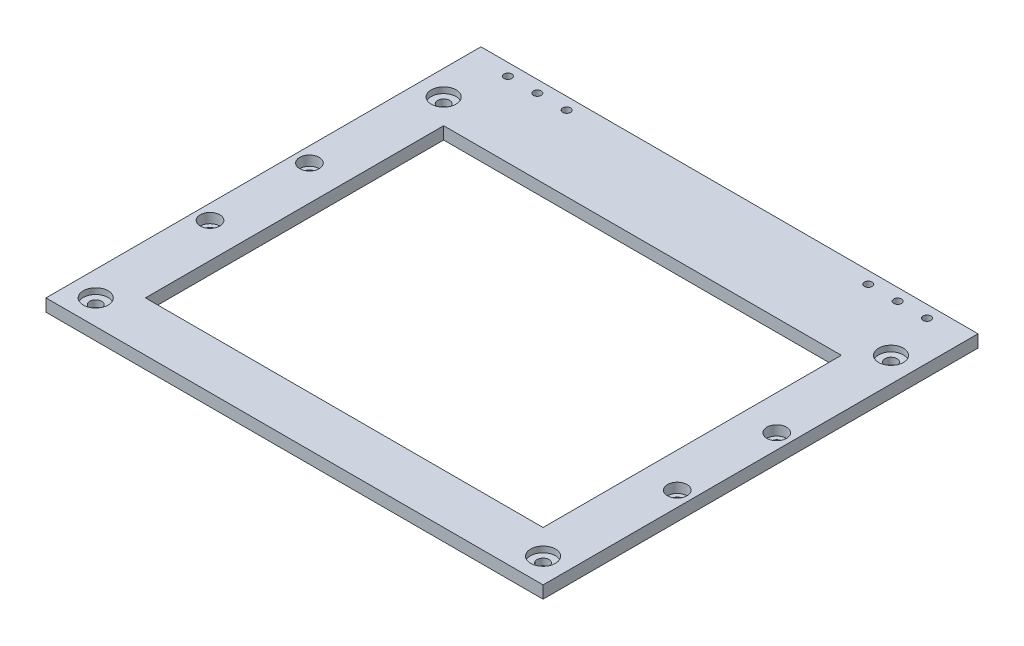
from build123d import *

# Parameters (mm, degrees)
SKETCH1_W                      = 254
SKETCH1_H                      = 203.2
SKETCH1_R                      = 3.05
SKETCH1_W_2                    = 203.2
SKETCH1_H_2                    = 152.4
BOSS_EXTRUDE1_DEPTH            = 6.35
SKETCH2_R                      = 6.35
CUT_EXTRUDE1_DEPTH             = 3
CBORE_FOR_M5_SHCS1_D           = 5.499989
CBORE_FOR_M5_SHCS1_CBORE_D     = 10
CBORE_FOR_M5_SHCS1_CBORE_DEPTH = 5
SKETCH5_W                      = 254
SKETCH5_H                      = 19.05
BOSS_EXTRUDE3_DEPTH            = 6.35
SKETCH6_R                      = 2
CUT_EXTRUDE2_DEPTH             = 4.5
SKETCH7_R                      = 1.75
CUT_EXTRUDE3_DEPTH             = 4.5


with BuildPart() as part:
    # Sketch1 → Boss-Extrude1 (new body)
    with BuildSketch(Plane(origin=(0, 0, 0), x_dir=(1, 0, 0), z_dir=(0, 1, 0))):
        with Locations((127, 101.6)):
            Rectangle(SKETCH1_W, SKETCH1_H)
        with Locations((12.7, 190.5)):
            Circle(SKETCH1_R, mode=Mode.SUBTRACT)
        with Locations((241.3, 190.5)):
            Circle(SKETCH1_R, mode=Mode.SUBTRACT)
        with Locations((241.3, 12.7)):
            Circle(SKETCH1_R, mode=Mode.SUBTRACT)
        with Locations((12.7, 12.7)):
            Circle(SKETCH1_R, mode=Mode.SUBTRACT)
        with Locations((127, 101.6)):
            Rectangle(SKETCH1_W_2, SKETCH1_H_2, mode=Mode.SUBTRACT)
    extrude(amount=BOSS_EXTRUDE1_DEPTH)

    # Sketch2 → Cut-Extrude1 (cut)
    with BuildSketch(Plane(origin=(0, 6.35, 0), x_dir=(1, 0, 0), z_dir=(0, 1, 0))):
        with Locations((12.7, 190.5)):
            Circle(SKETCH2_R)
        with Locations((241.3, 190.5)):
            Circle(SKETCH2_R)
        with Locations((241.3, 12.7)):
            Circle(SKETCH2_R)
        with Locations((12.7, 12.7)):
            Circle(SKETCH2_R)
    extrude(amount=-CUT_EXTRUDE1_DEPTH, mode=Mode.SUBTRACT)

    # CBORE for M5 SHCS1 (through all)
    with Locations(Plane(origin=(0, 6.35, 0), x_dir=(1, 0, 0), z_dir=(0, 1, 0))):
        with Locations((246.38, 76.2), (246.38, 127), (7.62, 76.2), (7.62, 127)):
            CounterBoreHole(CBORE_FOR_M5_SHCS1_D / 2, CBORE_FOR_M5_SHCS1_CBORE_D / 2, CBORE_FOR_M5_SHCS1_CBORE_DEPTH)

    # Sketch5 → Boss-Extrude3 (add)
    with BuildSketch(Plane.XZ):
        with Locations((127, -212.725)):
            Rectangle(SKETCH5_W, SKETCH5_H)
    extrude(amount=-BOSS_EXTRUDE3_DEPTH)

    # Sketch6 → Cut-Extrude2 (cut)
    with BuildSketch(Plane(origin=(0, 6.35, 0), x_dir=(1, 0, 0), z_dir=(0, 1, 0))):
        with Locations((19.924999942, 216.120415829)):
            Circle(SKETCH6_R)
        with Locations((34.924999942, 216.120415829)):
            Circle(SKETCH6_R)
        with Locations((49.936813619, 216.120415829)):
            Circle(SKETCH6_R)
        with Locations((204.063186381, 216.120415829)):
            Circle(SKETCH6_R)
        with Locations((219.075000058, 216.120415829)):
            Circle(SKETCH6_R)
        with Locations((234.075000058, 216.120415829)):
            Circle(SKETCH6_R)
    extrude(amount=-CUT_EXTRUDE2_DEPTH, mode=Mode.SUBTRACT)

    # Sketch7 → Cut-Extrude3 (cut)
    with BuildSketch(Plane(origin=(0, 1.85, 0), x_dir=(1, 0, 0), z_dir=(0, 1, 0))):
        with Locations((19.924999942, 216.120415829)):
            Circle(SKETCH7_R)
        with Locations((34.924999942, 216.120415829)):
            Circle(SKETCH7_R)
        with Locations((49.936813619, 216.120415829)):
            Circle(SKETCH7_R)
        with Locations((204.063186381, 216.120415829)):
            Circle(SKETCH7_R)
        with Locations((219.075000058, 216.120415829)):
            Circle(SKETCH7_R)
        with Locations((234.075000058, 216.120415829)):
            Circle(SKETCH7_R)
    extrude(amount=-CUT_EXTRUDE3_DEPTH, mode=Mode.SUBTRACT)


solid = part.part
